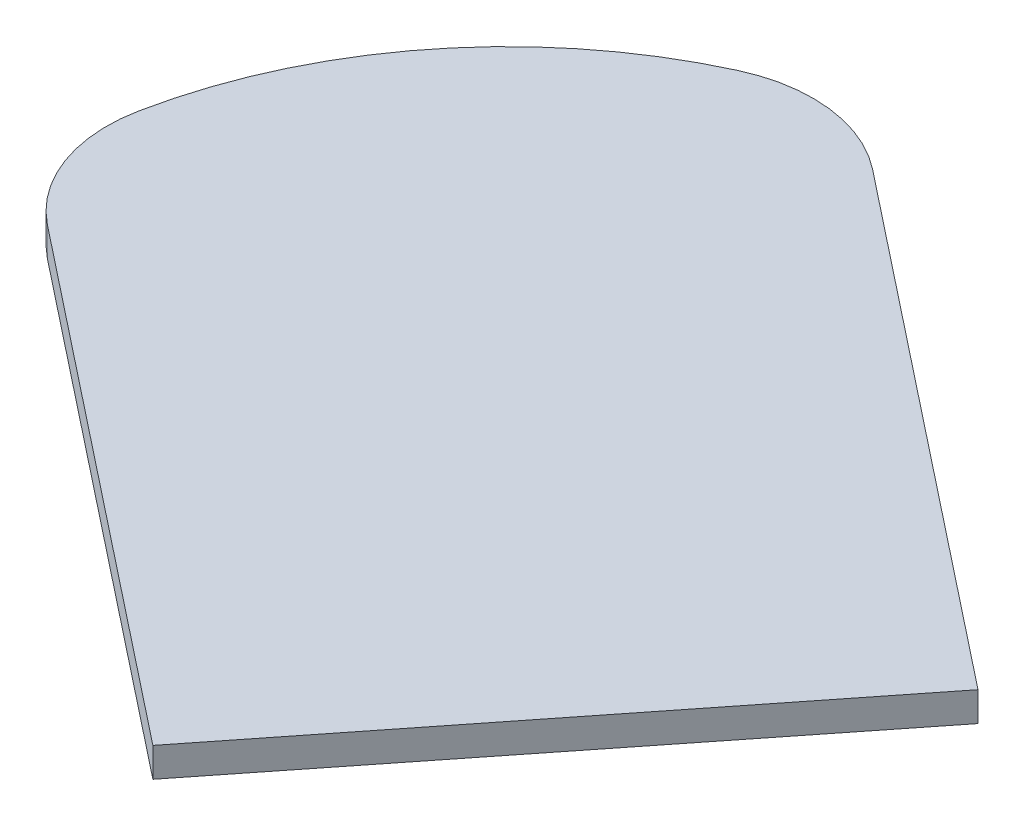
from build123d import *

# Parameters (mm, degrees)
BOSS_EXTRUDE1_DEPTH = 2


with BuildPart() as part:
    # Sketch1 → Boss-Extrude1 (new body)
    with BuildSketch(Plane(origin=(0, 0, 0), x_dir=(1, 0, 0), z_dir=(0, 1, 0))):
        with BuildLine():
            Line((-34.272006578, 2.022637666), (0.021174984, -25.087844423))
            Line((0.021174984, -25.087844423), (24.827751164, 6.291030289))
            Line((24.827751164, 6.291030289), (-9.465430397, 33.401512378))
            ThreePointArc((-9.465430397, 33.401512378), (-14.475065348, 35.485495243), (-19.835620944, 34.646525273))
            ThreePointArc((-19.835620944, 34.646525273), (-31.599371908, 25.404645185), (-37.876767257, 11.825525482))
            ThreePointArc((-37.876767257, 11.825525482), (-37.455913062, 6.416060752), (-34.272006578, 2.022637666))
        make_face()
    extrude(amount=BOSS_EXTRUDE1_DEPTH)


solid = part.part
